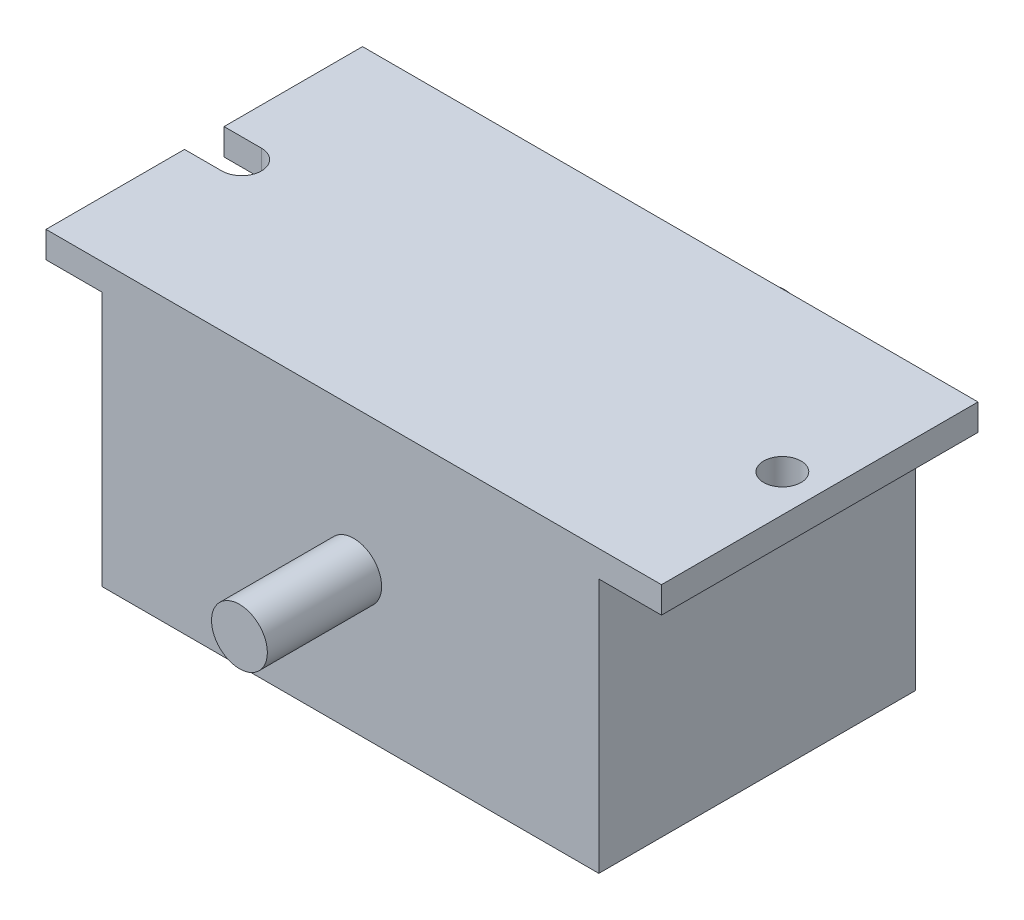
from build123d import *

# Parameters (mm, degrees)
BOSS_EXTRUDE1_DEPTH = 72
SKETCH2_R           = 4.25
CUT_EXTRUDE1_DEPTH  = 65
SKETCH3_R           = 6.35
BOSS_EXTRUDE2_DEPTH = 26
SKETCH5_R           = 6.35
BOSS_EXTRUDE3_DEPTH = 26


with BuildPart() as part:
    # Sketch1 → Boss-Extrude1 (new body)
    with BuildSketch(Plane.XY):
        Polygon((-56.490044248, 32.210989011), (58.009955752, 32.210989011), (70, 32.210989011), (70, 26.210989011), (55.75, 26.210989011), (55.75, -31.789010989), (-57.25, -31.789010989), (-57.25, 26.210989011), (-70, 26.210989011), (-70, 32.210989011), align=None)
    extrude(amount=BOSS_EXTRUDE1_DEPTH)

    # Sketch2 → Cut-Extrude1 (cut, through all)
    with BuildSketch(Plane(origin=(0, 32.210989011, 0), x_dir=(1, 0, 0), z_dir=(0, 1, 0))):
        with Locations((61.5, -36)):
            Circle(SKETCH2_R)
        with BuildLine():
            Line((-61.5, -31.5), (-70, -31.5))
            Line((-70, -31.5), (-70, -40.5))
            Line((-70, -40.5), (-61.5, -40.5))
            ThreePointArc((-61.5, -40.5), (-57, -36), (-61.5, -31.5))
        make_face()
    extrude(amount=-CUT_EXTRUDE1_DEPTH, mode=Mode.SUBTRACT)

    # Sketch3 → Boss-Extrude2 (add)
    with BuildSketch(Plane.XY.offset(72)):
        Circle(SKETCH3_R)
    extrude(amount=BOSS_EXTRUDE2_DEPTH)

    # Sketch5 → Boss-Extrude3 (add)
    with BuildSketch(Plane(origin=(0, 0, 0), x_dir=(-1, 0, 0), z_dir=(0, 0, -1))):
        Circle(SKETCH5_R)
    extrude(amount=BOSS_EXTRUDE3_DEPTH)


solid = part.part
